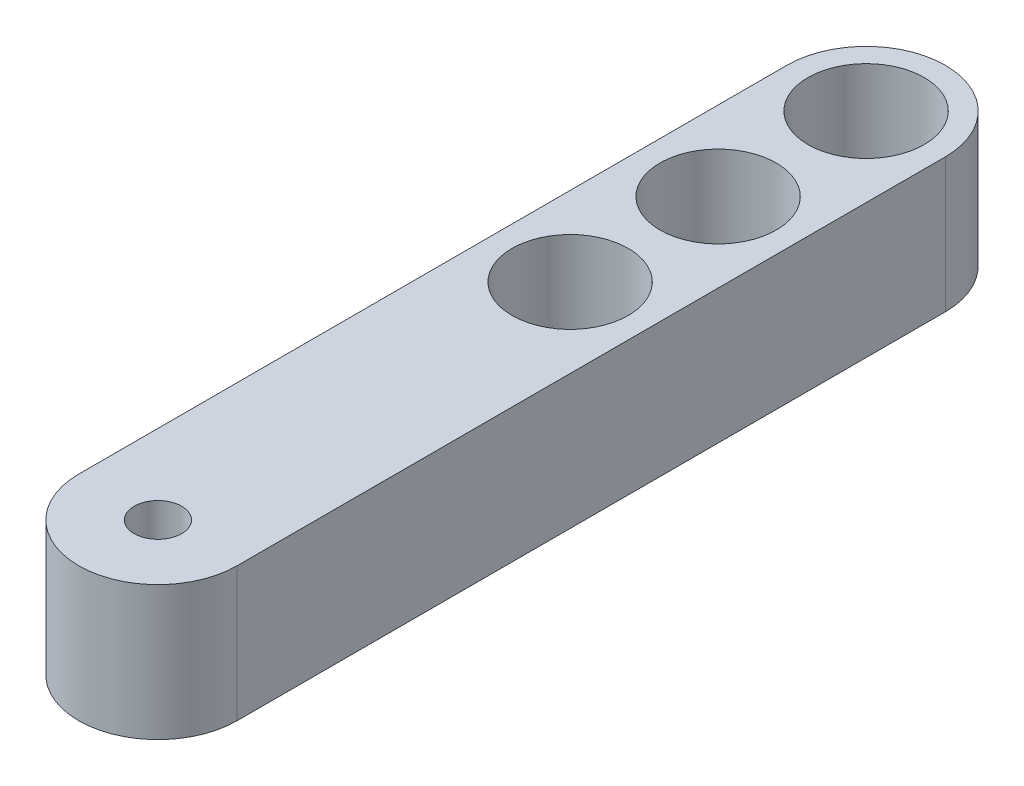
from build123d import *

# Parameters (mm, degrees)
SKETCH1_R           = 1.125
SKETCH1_R_2         = 2.75
BOSS_EXTRUDE1_DEPTH = 6.35
SKETCH2_R           = 2.75
CUT_EXTRUDE2_DEPTH  = 6.35


with BuildPart() as part:
    # Sketch1 → Boss-Extrude1 (new body)
    with BuildSketch(Plane(origin=(0, 0, 0), x_dir=(1, 0, 0), z_dir=(0, 1, 0))):
        with BuildLine():
            Line((-3.75, 33.5), (-3.75, 0))
            ThreePointArc((-3.75, 0), (0, -3.75), (3.75, 0))
            Line((3.75, 0), (3.75, 33.5))
            ThreePointArc((3.75, 33.5), (0, 37.25), (-3.75, 33.5))
        make_face()
        Circle(SKETCH1_R, mode=Mode.SUBTRACT)
        with Locations((0, 33.5)):
            Circle(SKETCH1_R_2, mode=Mode.SUBTRACT)
    extrude(amount=BOSS_EXTRUDE1_DEPTH)

    # Sketch2 → Cut-Extrude2 (cut)
    with BuildSketch(Plane(origin=(0, 0, 0), x_dir=(1, 0, 0), z_dir=(0, 1, 0))):
        with Locations((0, 33.5)):
            Circle(SKETCH2_R)
        with Locations((0, 19.5)):
            Circle(SKETCH2_R)
        with Locations((0, 26.5)):
            Circle(SKETCH2_R)
    extrude(amount=CUT_EXTRUDE2_DEPTH, mode=Mode.SUBTRACT)


solid = part.part
